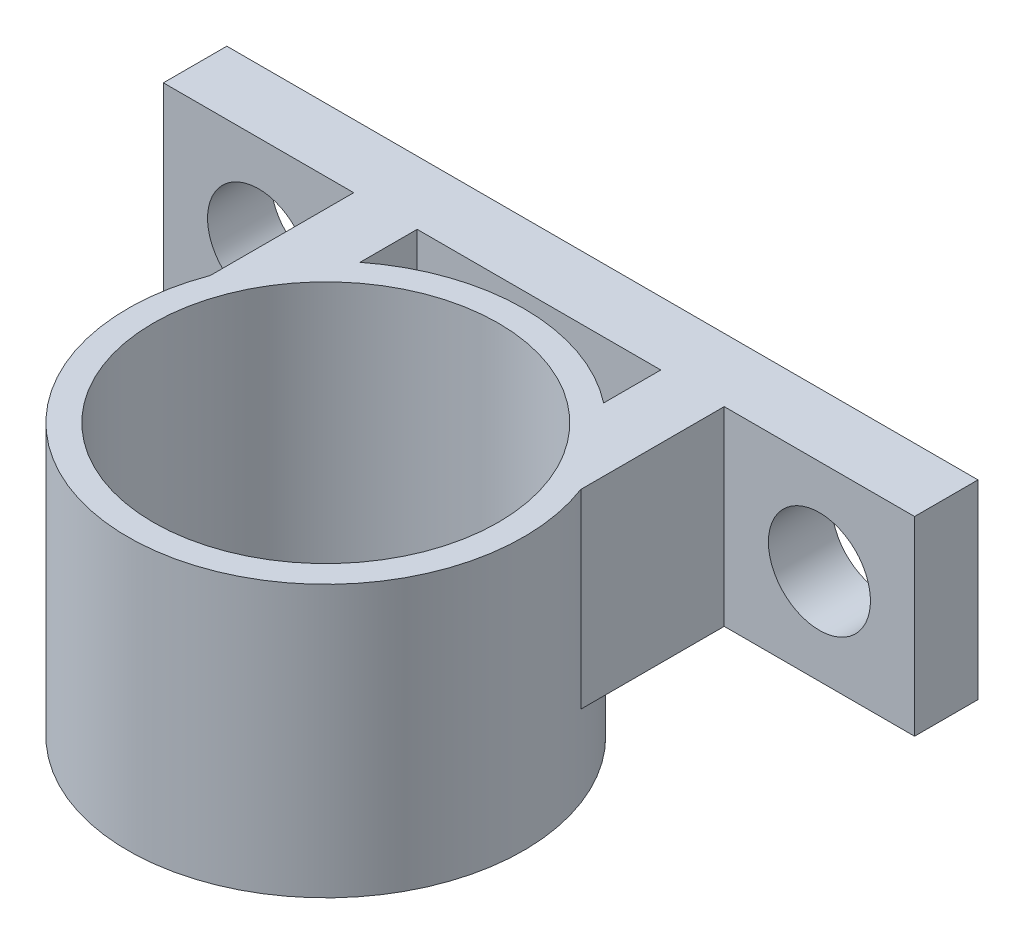
from build123d import *

# Parameters (mm, degrees)
SKETCH1_R           = 6.096
BOSS_EXTRUDE1_DEPTH = 9.525
SKETCH2_R           = 2.5527
CUT_EXTRUDE1_DEPTH  = 4.175
SKETCH3_R           = 9.271
SKETCH3_R_2         = 6.096
BOSS_EXTRUDE2_DEPTH = 2.794
SKETCH6_R           = 9.906
SKETCH6_R_2         = 8.636
BOSS_EXTRUDE4_DEPTH = 12.319
SKETCH5_R           = 8.636
CUT_EXTRUDE2_DEPTH  = 12.319
SKETCH4_R           = 9.906
SKETCH4_R_2         = 7.366
BOSS_EXTRUDE3_DEPTH = 1.27


with BuildPart() as part:
    # Sketch1 → Boss-Extrude1 (new body)
    with BuildSketch(Plane(origin=(0, 0, 0), x_dir=(1, 0, 0), z_dir=(0, 1, 0))):
        with BuildLine():
            Line((-9.271, 0), (-9.271, 10.668))
            Line((-9.271, 10.668), (-18.796, 10.668))
            Line((-18.796, 10.668), (-18.796, 13.843))
            Line((-18.796, 13.843), (-6.096, 13.843))
            Line((-6.096, 13.843), (6.096, 13.843))
            Line((6.096, 13.843), (18.796, 13.843))
            Line((18.796, 13.843), (18.796, 10.668))
            Line((18.796, 10.668), (9.271, 10.668))
            Line((9.271, 10.668), (9.271, 0))
            ThreePointArc((9.271, 0), (0, -9.271), (-9.271, 0))
        make_face()
        Circle(SKETCH1_R, mode=Mode.SUBTRACT)
        with BuildLine():
            Line((-6.096, 6.731), (-6.096, 10.668))
            Line((-6.096, 10.668), (6.096, 10.668))
            Line((6.096, 10.668), (6.096, 6.731))
            ThreePointArc((6.096, 6.731), (0, 9.081166059), (-6.096, 6.731))
        make_face(mode=Mode.SUBTRACT)
    extrude(amount=BOSS_EXTRUDE1_DEPTH)

    # Sketch2 → Cut-Extrude1 (cut, through all)
    with BuildSketch(Plane.XY.offset(-10.668)):
        with Locations((-14.0335, 4.7625)):
            Circle(SKETCH2_R)
        with Locations((14.0335, 4.7625)):
            Circle(SKETCH2_R)
    extrude(amount=-CUT_EXTRUDE1_DEPTH, mode=Mode.SUBTRACT)

    # Sketch3 → Boss-Extrude2 (add)
    with BuildSketch(Plane(origin=(0, 0, 0), x_dir=(-1, 0, 0), z_dir=(0, -1, 0))):
        Circle(SKETCH3_R)
        Circle(SKETCH3_R_2, mode=Mode.SUBTRACT)
    extrude(amount=BOSS_EXTRUDE2_DEPTH)

    # Sketch6 → Boss-Extrude4 (add)
    with BuildSketch(Plane(origin=(0, 9.525, 0), x_dir=(1, 0, 0), z_dir=(0, 1, 0))):
        Circle(SKETCH6_R)
        Circle(SKETCH6_R_2, mode=Mode.SUBTRACT)
    extrude(amount=-BOSS_EXTRUDE4_DEPTH)

    # Sketch5 → Cut-Extrude2 (cut)
    with BuildSketch(Plane(origin=(0, 9.525, 0), x_dir=(1, 0, 0), z_dir=(0, 1, 0))):
        Circle(SKETCH5_R)
    extrude(amount=-CUT_EXTRUDE2_DEPTH, mode=Mode.SUBTRACT)

    # Sketch4 → Boss-Extrude3 (add)
    with BuildSketch(Plane(origin=(0, -2.794, 0), x_dir=(-1, 0, 0), z_dir=(0, -1, 0))):
        Circle(SKETCH4_R)
        Circle(SKETCH4_R_2, mode=Mode.SUBTRACT)
    extrude(amount=BOSS_EXTRUDE3_DEPTH)


solid = part.part
